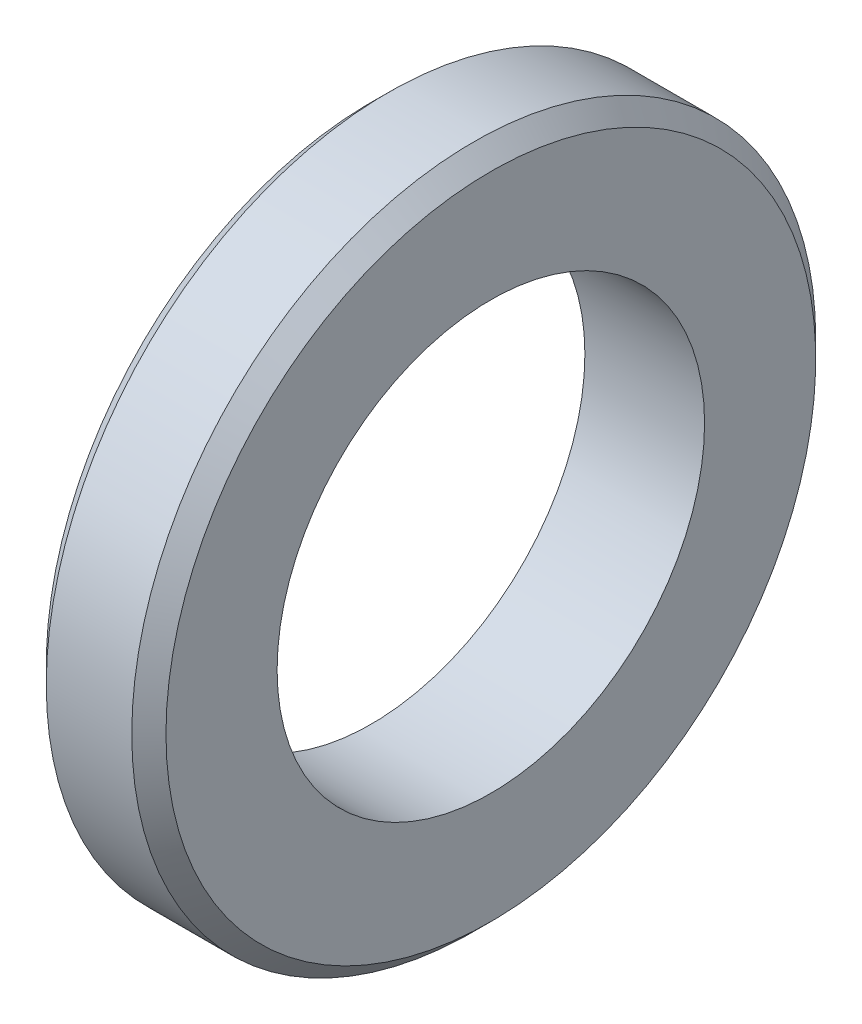
from build123d import *

# Parameters (mm, degrees)
SKETCH1_W     = 1.4
SKETCH1_H     = 1.5
CHAMFER1_SIZE = 0.2


with BuildPart() as part:
    # Sketch1 → Revolve1 (revolve)
    with BuildSketch(Plane.XY, mode=Mode.PRIVATE) as revolve1_sk:
        with Locations((0.7, 3.25)):
            Rectangle(SKETCH1_W, SKETCH1_H)
    revolve(revolve1_sk.sketch.rotate(Axis((0, 0, 0), (1, 0, 0)), 90), axis=Axis((0, 0, 0), (1, 0, 0)))

    # Chamfer1
    chamfer1_edges = [part.edges().sort_by_distance(p)[0] for p in [
        (1.4, 0, -4),
        (0, 0, -4),
    ]]
    chamfer(chamfer1_edges, length=CHAMFER1_SIZE)


solid = part.part
